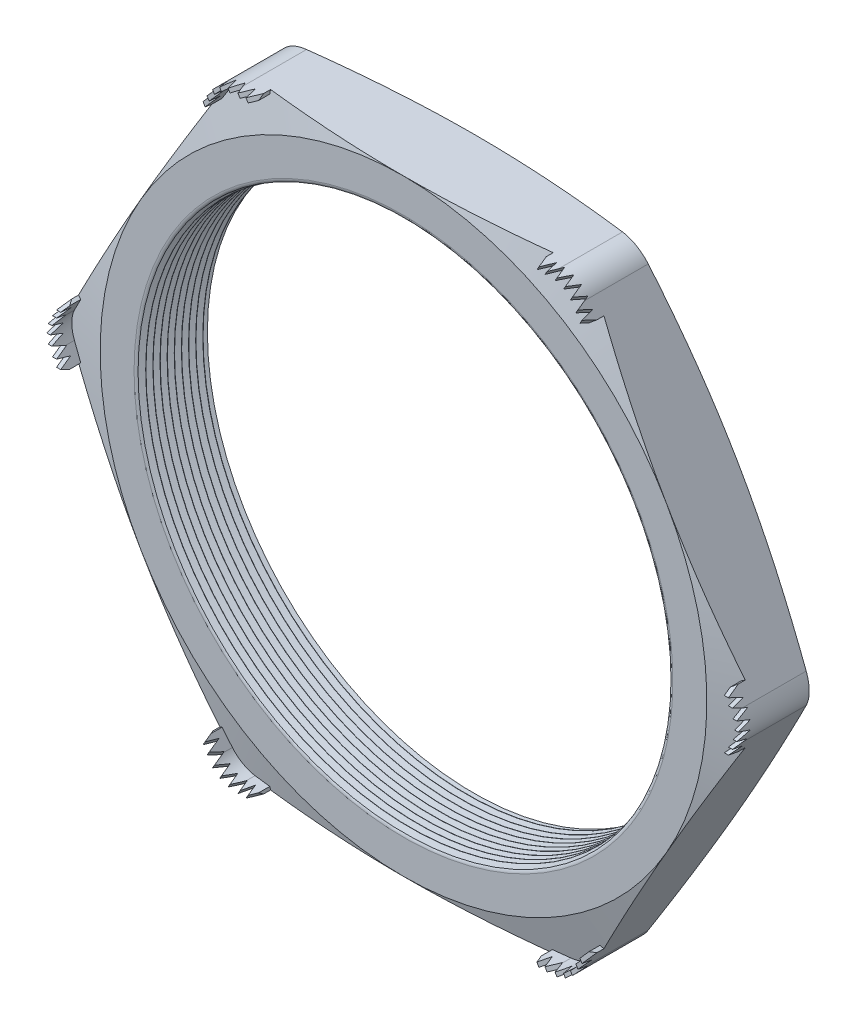
from build123d import *

# Parameters (mm, degrees)
SKETCH1_R          = 11.303
EXTRUDE1_DEPTH     = 3.048
FILLET1_R          = 1.27
FILLET3_R          = 0.2032
LPATTERN1_COUNT    = 10
LPATTERN1_PITCH    = 0.3048
SKETCH4_OUTSIDE_W  = 69.618
SKETCH4_OUTSIDE_H  = 66.002
SKETCH4_OUTSIDE_R  = 12.954
CUT_EXTRUDE1_DEPTH = 4.048
CUT_EXTRUDE1_DRAFT = -75
SKETCH5_OUTSIDE_W  = 69.618
SKETCH5_OUTSIDE_H  = 66.002
SKETCH5_OUTSIDE_R  = 12.954
CUT_EXTRUDE2_DEPTH = 4.0480001
CUT_EXTRUDE2_DRAFT = -75
EXTRUDE2_START     = -0.484324
EXTRUDE2_DEPTH     = 1.754324
CUT_EXTRUDE4_DEPTH = 5.495462681
CIRPATTERN1_COUNT  = 6
CIRPATTERN2_COUNT  = 6


with BuildPart() as part:
    # Sketch1 → Extrude1 (new body)
    with BuildSketch(Plane.XY):
        Polygon((-14.957990774, 0), (-7.478995387, -12.954), (7.478995387, -12.954), (14.957990774, 0), (7.478995387, 12.954), (-7.478995387, 12.954), align=None)
        Circle(SKETCH1_R, mode=Mode.SUBTRACT)
    extrude(amount=EXTRUDE1_DEPTH)

    # Fillet1
    fillet1_edges = [part.edges().sort_by_distance(p)[0] for p in [
        (14.957990774, 0, 1.524),
        (7.478995387, -12.954, 1.524),
        (-7.478995387, -12.954, 1.524),
        (-14.957990774, 0, 1.524),
        (-7.478995387, 12.954, 1.524),
        (7.478995387, 12.954, 1.524),
    ]]
    fillet(fillet1_edges, radius=FILLET1_R)

    # Fillet3
    fillet3_edges = [part.edges().sort_by_distance(p)[0] for p in [
        (-11.303, 0, 0),
        (-11.303, 0, 3.048),
    ]]
    fillet(fillet3_edges, radius=FILLET3_R)

    # Sketch3 → Cut-Revolve1 (revolve, cut)
    with BuildSketch(Plane(origin=(0, 0, 0), x_dir=(1, 0, 0), z_dir=(0, 1, 0))):
        Polygon((-11.303, -3.048), (-11.303, -2.754706063), (-11.557, -2.901353032), align=None)
    cut_revolve1 = revolve(axis=Axis((0, 0, 3.048), (0, 0, -1)), mode=Mode.SUBTRACT)

    # LPattern1: Cut-Revolve1 ×10
    with Locations(*[(0, 0, -i * LPATTERN1_PITCH) for i in range(1, LPATTERN1_COUNT)]):
        add(cut_revolve1, mode=Mode.SUBTRACT)


with BuildPart() as cut_extrude1_tool:
    # Sketch4 outside → Cut-Extrude1 (with draft: the straight prism first)
    with BuildSketch(Plane(origin=(0, 0, 0), x_dir=(-1, 0, 0), z_dir=(0, 0, -1))):
        Rectangle(SKETCH4_OUTSIDE_W, SKETCH4_OUTSIDE_H)
        Circle(SKETCH4_OUTSIDE_R, mode=Mode.SUBTRACT)
    extrude(amount=-CUT_EXTRUDE1_DEPTH)
    # Cut-Extrude1: the draft: its side faces are tilted about the plane it starts from
    cut_extrude1_sides = [cut_extrude1_tool.faces().sort_by_distance(p)[0] for p in [
        (0, -33.001, 2.024),
        (-34.809, 0, 2.024),
        (0, 33.001, 2.024),
        (34.809, 0, 2.024),
        (12.954, 0, 2.024),
    ]]
    draft(cut_extrude1_sides, Plane(origin=(0, 0, 0), x_dir=(-1, 0, 0), z_dir=(0, 0, -1)), CUT_EXTRUDE1_DRAFT)


with BuildPart() as part_1:
    add(part.part)

    # Cut-Extrude1: cut by cut_extrude1_tool
    add(cut_extrude1_tool.part, mode=Mode.SUBTRACT)


with BuildPart() as cut_extrude2_tool:
    # Sketch5 outside → Cut-Extrude2 (with draft: the straight prism first)
    with BuildSketch(Plane.XY.offset(3.048)):
        Rectangle(SKETCH5_OUTSIDE_W, SKETCH5_OUTSIDE_H)
        Circle(SKETCH5_OUTSIDE_R, mode=Mode.SUBTRACT)
    extrude(amount=-CUT_EXTRUDE2_DEPTH)
    # Cut-Extrude2: the draft: its side faces are tilted about the plane it starts from
    cut_extrude2_sides = [cut_extrude2_tool.faces().sort_by_distance(p)[0] for p in [
        (0, -33.001, 1.02399995),
        (34.809, 0, 1.02399995),
        (0, 33.001, 1.02399995),
        (-34.809, 0, 1.02399995),
        (-12.954, 0, 1.02399995),
    ]]
    draft(cut_extrude2_sides, Plane.XY.offset(3.048), CUT_EXTRUDE2_DRAFT)


with BuildPart() as part_2:
    add(part_1.part)

    # Cut-Extrude2: cut by cut_extrude2_tool
    add(cut_extrude2_tool.part, mode=Mode.SUBTRACT)

    # Sketch2 → Extrude2 (add)
    with BuildSketch(Plane.XY.offset(3.048).offset(EXTRUDE2_START)):
        with BuildLine():
            Line((-6.745760545, 12.954), (-6.034560545, 12.954))
            Line((-6.034560545, 12.954), (-6.034560545, 12.8016))
            Line((-6.034560545, 12.8016), (-6.745760545, 12.8016))
            ThreePointArc((-6.745760545, 12.8016), (-7.304560545, 12.651869991), (-7.713630536, 12.2428))
            Line((-7.713630536, 12.2428), (-8.069230536, 11.626882733))
            Line((-8.069230536, 11.626882733), (-8.201212808, 11.703082733))
            Line((-8.201212808, 11.703082733), (-7.845612808, 12.319))
            ThreePointArc((-7.845612808, 12.319), (-7.380760545, 12.783852263), (-6.745760545, 12.954))
        make_face()
    extrude2 = extrude(amount=EXTRUDE2_DEPTH)

    # Sketch7 → Cut-Extrude4 (cut, through all)
    with BuildSketch(Plane(origin=(-7.051895541, 12.214241366, 0), x_dir=(0.866025404, 0.5, 0), z_dir=(0.5, -0.866025404, 0))):
        Polygon((-1.250917267, 2.9845), (-1.060417267, 3.5179), (-0.869917267, 2.9845), (-0.762, 3.5179), (-0.5715, 2.9845), (-0.381, 3.5179), (-0.1905, 2.9845), (0, 3.5179), (0.1905, 2.9845), (0.381, 3.5179), (0.5715, 2.9845), (0.762, 3.5179), (0.9525, 2.9845), (1.060417267, 3.5179), (1.250917267, 2.9845), (1.250917267, 4.318), (-1.250917267, 4.318), align=None)
    cut_extrude4 = extrude(amount=-CUT_EXTRUDE4_DEPTH, mode=Mode.SUBTRACT)

    # CirPattern1: Extrude2 ×6 about axis
    cirpattern1_axis = Axis((0, 0, 0), (0, 0, 1))
    for i in range(1, CIRPATTERN1_COUNT):
        add(extrude2.rotate(cirpattern1_axis, i * 360 / CIRPATTERN1_COUNT))

    # CirPattern2: Cut-Extrude4 ×6 about axis
    cirpattern2_axis = Axis((0, 0, 0), (0, 0, 1))
    for i in range(1, CIRPATTERN2_COUNT):
        add(cut_extrude4.rotate(cirpattern2_axis, i * 360 / CIRPATTERN2_COUNT), mode=Mode.SUBTRACT)


solid = part_2.part
